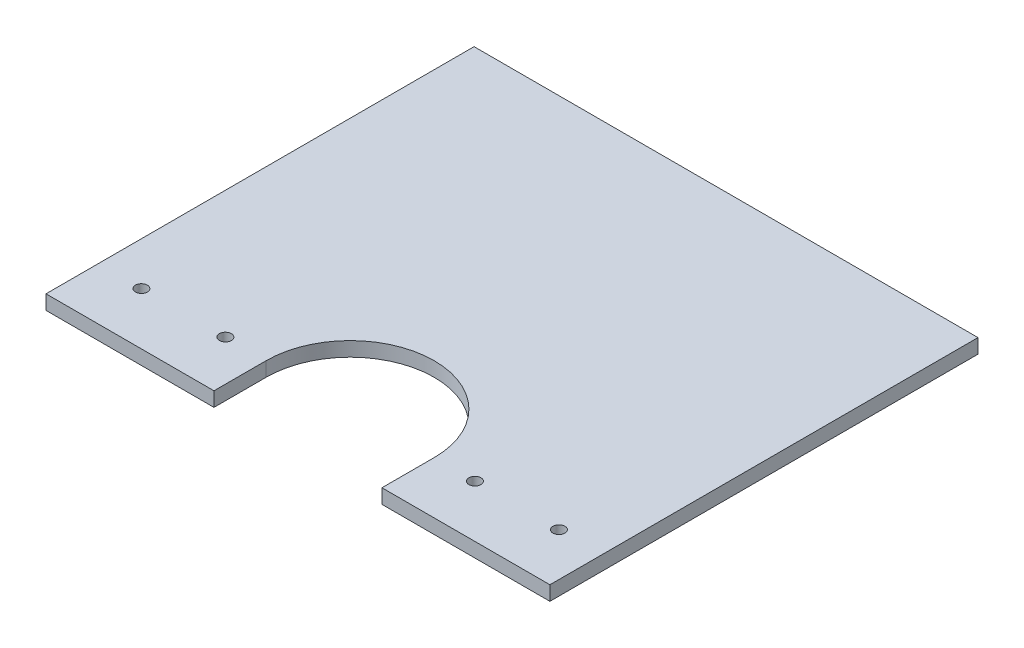
from build123d import *

# Parameters (mm, degrees)
MODEL_R             = 2.5
BOSS_EXTRUDE1_DEPTH = 3


with BuildPart() as part:
    # Model → Boss-Extrude1 (new body, symmetric)
    with BuildSketch(Plane(origin=(0, 0, 0), x_dir=(1, 0, 0), z_dir=(0, 1, 0))):
        with BuildLine():
            Line((-34.997168674, -67.443546623), (-34.999805804, -89.200353377))
            Line((-34.999805804, -89.200353377), (-104.999287788, -89.200353377))
            Line((-104.999287788, -89.200353377), (-105.000194196, 89.200353377))
            Line((-105.000194196, 89.200353377), (104.999740995, 89.200353377))
            Line((104.999740995, 89.200353377), (104.999740995, -89.200353377))
            Line((104.999740995, -89.200353377), (35.000194196, -89.200353377))
            Line((35.000194196, -89.200353377), (35.002831326, -67.443546623))
            ThreePointArc((35.002831326, -67.443546623), (0.002831326, -32.443546623), (-34.997168674, -67.443546623))
        make_face()
        with Locations((52.000194196, -67.443546623)):
            Circle(MODEL_R, mode=Mode.SUBTRACT)
        with Locations((-51.999805804, -67.443546623)):
            Circle(MODEL_R, mode=Mode.SUBTRACT)
        with Locations((-86.999805804, -67.443546623)):
            Circle(MODEL_R, mode=Mode.SUBTRACT)
        with Locations((87.000194196, -67.443546623)):
            Circle(MODEL_R, mode=Mode.SUBTRACT)
    extrude(amount=BOSS_EXTRUDE1_DEPTH, both=True)


solid = part.part
